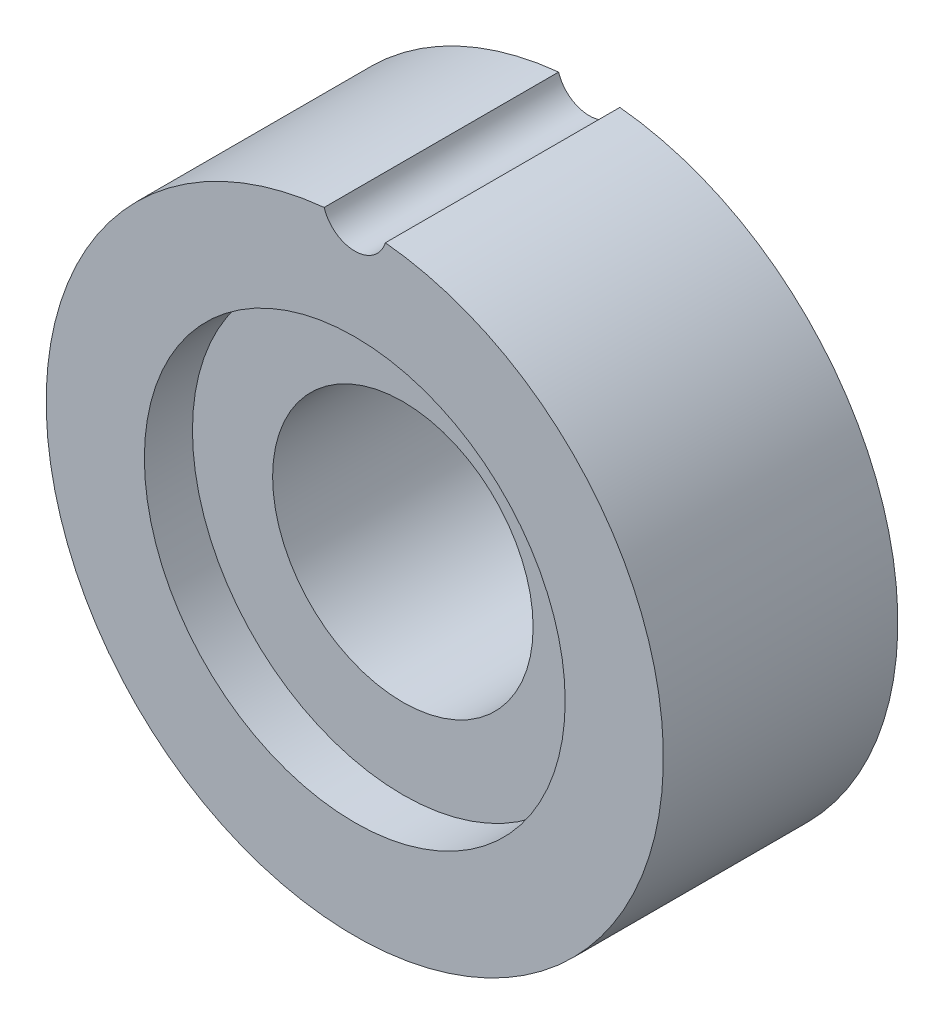
from build123d import *

# Parameters (mm, degrees)
SKETCH1_R           = 7.7
SKETCH1_R_2         = 3.25
BOSS_EXTRUDE1_DEPTH = 5.85
SKETCH2_R           = 5.25
CUT_EXTRUDE1_DEPTH  = 1.2
SKETCH3_R           = 0.8
CUT_EXTRUDE2_DEPTH  = 10


with BuildPart() as part:
    # Sketch1 → Boss-Extrude1 (new body)
    with BuildSketch(Plane.XY):
        Circle(SKETCH1_R)
        Circle(SKETCH1_R_2, mode=Mode.SUBTRACT)
    extrude(amount=BOSS_EXTRUDE1_DEPTH)

    # Sketch2 → Cut-Extrude1 (cut)
    with BuildSketch(Plane.XY.offset(5.85)):
        Circle(SKETCH2_R)
    extrude(amount=-CUT_EXTRUDE1_DEPTH, mode=Mode.SUBTRACT)

    # Sketch3 → Cut-Extrude2 (cut)
    with BuildSketch(Plane(origin=(0, 0, 0), x_dir=(-1, 0, 0), z_dir=(0, 0, -1))):
        with Locations((0, 7.9)):
            Circle(SKETCH3_R)
    extrude(amount=-CUT_EXTRUDE2_DEPTH, mode=Mode.SUBTRACT)


solid = part.part
